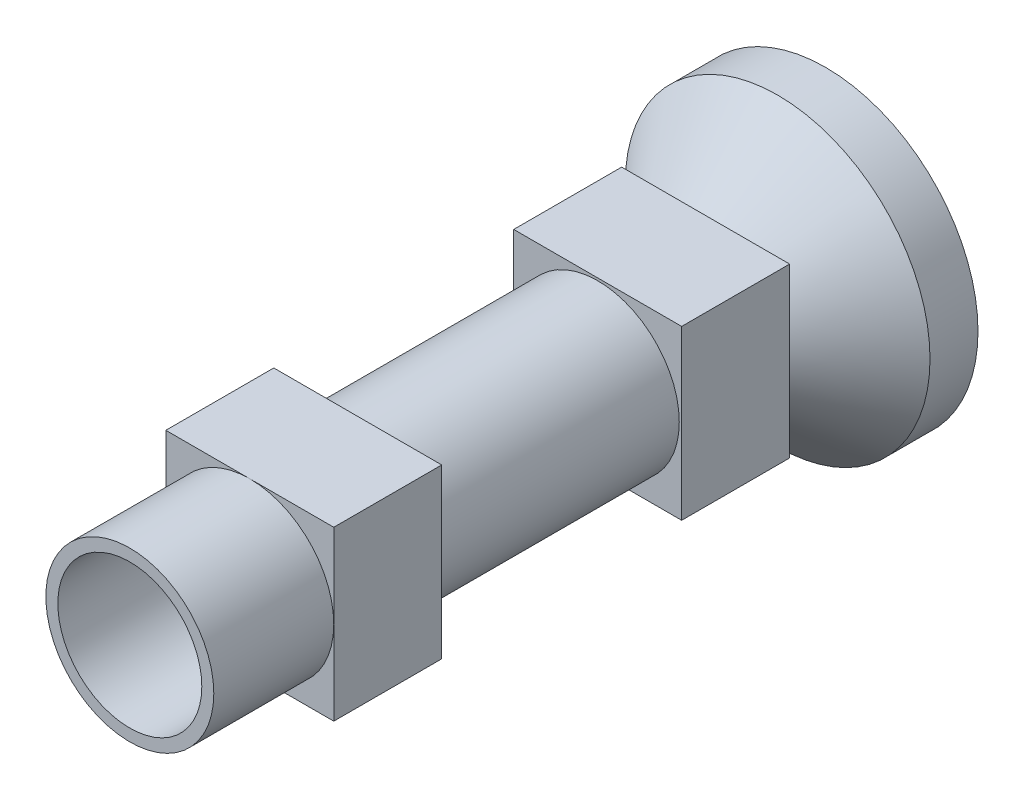
from build123d import *

# Parameters (mm, degrees)
SKETCH_2_R               = 3.5
EXTRUDE_3_DEPTH          = 19
SKETCH_1_R               = 6.35
EXTRUDE_4_DEPTH          = 2
SKETCH_5_R               = 3.5
EXTRUDE_5_DEPTH          = 2
SKETCH_6_R               = 2.75
CUT_EXTRUDE_1_DEPTH      = 3
SKETCH_7_R               = 1.8
CUT_EXTRUDE_2_DEPTH      = 28.507180927
SKETCH_8_R               = 3
CUT_EXTRUDE_3_DEPTH      = 23
CUT_EXTRUDE_5_DEPTH      = 3
SKETCH_14_W              = 7
SKETCH_14_H              = 7
SKETCH_14_R              = 3.4
EXTRUDE_7_DEPTH          = 19
SKETCH_16_W              = 7
SKETCH_16_H              = 7
SKETCH_16_R              = 3.4
CUT_EXTRUDE_6_DEPTH      = 5
CUT_EXTRUDE_6_DEPTH_BACK = 5
SKETCH_17_R              = 3
SKETCH_17_R_2            = 1.8
EXTRUDE_8_DEPTH          = 14


with BuildPart() as part:
    # ｽｹｯﾁ2 → ﾎﾞｽ - 押し出し3 (new body)
    with BuildSketch(Plane.XY.offset(5)):
        with Locations(Location((0, 0, 0), (0, 0, 180))):
            Circle(SKETCH_2_R)
    extrude(amount=EXTRUDE_3_DEPTH)


with BuildPart() as body_2:
    # ｽｹｯﾁ1 → ﾎﾞｽ - 押し出し4 (new body)
    with BuildSketch(Plane.XY):
        Circle(SKETCH_1_R)
    extrude(amount=EXTRUDE_4_DEPTH)


    add(part.part)  # loft_1 joins it to this body
    # loft from a face of the part (loft_1)
    loft([body_2.faces().sort_by_distance((0, 0, 2))[0], body_2.faces().sort_by_distance((0, 0, 5))[0]])



with BuildPart() as body_3:
    # ｽｹｯﾁ5 → ﾎﾞｽ - 押し出し5 (new body)
    with BuildSketch(Plane.XY.offset(29)):
        Circle(SKETCH_5_R)
    extrude(amount=-EXTRUDE_5_DEPTH)


with BuildPart() as body_2_1:
    add(body_2.part)

    add(body_3.part)  # loft_2 joins it to this body
    # loft from a face of the part (loft_2)
    loft([body_2_1.faces().sort_by_distance((0, 0, 24))[0], body_2_1.faces().sort_by_distance((0, 0, 27))[0]])

    # ｽｹｯﾁ6 → ｶｯﾄ - 押し出し1 (cut)
    with BuildSketch(Plane(origin=(0, 0, 0), x_dir=(-1, 0, 0), z_dir=(0, 0, -1))):
        Circle(SKETCH_6_R)
    extrude(amount=-CUT_EXTRUDE_1_DEPTH, mode=Mode.SUBTRACT)

    # ｽｹｯﾁ7 → ｶｯﾄ - 押し出し2 (cut, through all)
    with BuildSketch(Plane(origin=(0, 0, 3), x_dir=(-1, 0, 0), z_dir=(0, 0, -1))):
        Circle(SKETCH_7_R)
    extrude(amount=-CUT_EXTRUDE_2_DEPTH, mode=Mode.SUBTRACT)

    # ｽｹｯﾁ8 → ｶｯﾄ - 押し出し3 (cut)
    with BuildSketch(Plane.XY.offset(29)):
        Circle(SKETCH_8_R)
    extrude(amount=-CUT_EXTRUDE_3_DEPTH, mode=Mode.SUBTRACT)

    # ｽｹｯﾁ12 → ｶｯﾄ - 押し出し5 (cut)
    with BuildSketch(Plane(origin=(0, 0, 0), x_dir=(-1, 0, 0), z_dir=(0, 0, -1))):
        with BuildLine():
            Line((0.208139361, 3.042889746), (-0.062598794, 2.749287433))
            ThreePointArc((-0.062598794, 2.749287433), (0.187666637, 2.743589115), (0.436377003, 2.715156554))
            Line((0.436377003, 2.715156554), (0.208139361, 3.042889746))
        make_face()
        with BuildLine():
            Line((1.021382817, 2.873895812), (0.681471411, 2.66422535))
            ThreePointArc((0.681471411, 2.66422535), (0.920918933, 2.591217536), (1.152735431, 2.496738077))
            Line((1.152735431, 2.496738077), (1.021382817, 2.873895812))
        make_face()
        with BuildLine():
            Line((1.758874982, 2.491758174), (1.375, 2.38156986))
            ThreePointArc((1.375, 2.38156986), (1.585870886, 2.246667206), (1.783600746, 2.093147959))
            Line((1.783600746, 2.093147959), (1.758874982, 2.491758174))
        make_face()
        with BuildLine():
            Line((2.365919437, 1.92481823), (1.966551129, 1.922284229))
            ThreePointArc((1.966551129, 1.922284229), (2.133206049, 1.735491847), (2.282184553, 1.534318633))
            Line((2.282184553, 1.534318633), (2.365919437, 1.92481823))
        make_face()
        with BuildLine():
            Line((2.79749447, 1.215123324), (2.412252157, 1.320431571))
            ThreePointArc((2.412252157, 1.320431571), (2.522331079, 1.095602997), (2.611509172, 0.861695912))
            Line((2.611509172, 0.861695912), (2.79749447, 1.215123324))
        make_face()
        with BuildLine():
            Line((3.021592135, 0.41530828), (2.679047477, 0.620648543))
            ThreePointArc((2.679047477, 0.620648543), (2.724386352, 0.374458285), (2.747150103, 0.125165148))
            Line((2.747150103, 0.125165148), (3.021592135, 0.41530828))
        make_face()
        with BuildLine():
            Line((3.021592135, -0.41530828), (2.747150103, -0.125165148))
            ThreePointArc((2.747150103, -0.125165148), (2.724386352, -0.374458285), (2.679047477, -0.620648543))
            Line((2.679047477, -0.620648543), (3.021592135, -0.41530828))
        make_face()
        with BuildLine():
            Line((2.79749447, -1.215123324), (2.611509172, -0.861695912))
            ThreePointArc((2.611509172, -0.861695912), (2.522331079, -1.095602997), (2.412252157, -1.320431571))
            Line((2.412252157, -1.320431571), (2.79749447, -1.215123324))
        make_face()
        with BuildLine():
            Line((2.365919437, -1.92481823), (2.282184553, -1.534318633))
            ThreePointArc((2.282184553, -1.534318633), (2.133206049, -1.735491847), (1.966551129, -1.922284229))
            Line((1.966551129, -1.922284229), (2.365919437, -1.92481823))
        make_face()
        with BuildLine():
            Line((1.758874982, -2.491758174), (1.783600746, -2.093147959))
            ThreePointArc((1.783600746, -2.093147959), (1.585870886, -2.246667206), (1.375, -2.38156986))
            Line((1.375, -2.38156986), (1.758874982, -2.491758174))
        make_face()
        with BuildLine():
            Line((1.021382817, -2.873895812), (1.152735431, -2.496738077))
            ThreePointArc((1.152735431, -2.496738077), (0.920918933, -2.591217536), (0.681471411, -2.66422535))
            Line((0.681471411, -2.66422535), (1.021382817, -2.873895812))
        make_face()
        with BuildLine():
            Line((0.208139361, -3.042889746), (0.436377003, -2.715156554))
            ThreePointArc((0.436377003, -2.715156554), (0.187666637, -2.743589115), (-0.062598794, -2.749287433))
            Line((-0.062598794, -2.749287433), (0.208139361, -3.042889746))
        make_face()
        with BuildLine():
            Line((-0.62054084, -2.986206467), (-0.312345512, -2.73220429))
            ThreePointArc((-0.312345512, -2.73220429), (-0.559504036, -2.692481241), (-0.802026334, -2.630447445))
            Line((-0.802026334, -2.630447445), (-0.62054084, -2.986206467))
        make_face()
        with BuildLine():
            Line((-1.403198365, -2.708049916), (-1.037902788, -2.546616933))
            ThreePointArc((-1.037902788, -2.546616933), (-1.265178854, -2.441684351), (-1.481971249, -2.316519203))
            Line((-1.481971249, -2.316519203), (-1.403198365, -2.708049916))
        make_face()
        with BuildLine():
            Line((-2.081787087, -2.229049691), (-1.686483563, -2.172158648))
            ThreePointArc((-1.686483563, -2.172158648), (-1.877021144, -2.009798902), (-2.052005136, -1.830785329))
            Line((-2.052005136, -1.830785329), (-2.081787087, -2.229049691))
        make_face()
        with BuildLine():
            Line((-2.605979184, -1.584731048), (-2.209985568, -1.636601293))
            ThreePointArc((-2.209985568, -1.636601293), (-2.349653363, -1.428855863), (-2.46985119, -1.209270483))
            Line((-2.46985119, -1.209270483), (-2.605979184, -1.584731048))
        make_face()
        with BuildLine():
            Line((-2.936897726, -0.822880152), (-2.569583052, -0.979664707))
            ThreePointArc((-2.569583052, -0.979664707), (-2.64802254, -0.741941121), (-2.704519679, -0.498069577))
            Line((-2.704519679, -0.498069577), (-2.936897726, -0.822880152))
        make_face()
        with BuildLine():
            Line((-3.05, 0), (-2.738606317, -0.250070871))
            ThreePointArc((-2.738606317, -0.250070871), (-2.75, 0), (-2.738606317, 0.250070871))
            Line((-2.738606317, 0.250070871), (-3.05, 0))
        make_face()
        with BuildLine():
            Line((-2.936897726, 0.822880152), (-2.704519679, 0.498069577))
            ThreePointArc((-2.704519679, 0.498069577), (-2.64802254, 0.741941121), (-2.569583052, 0.979664707))
            Line((-2.569583052, 0.979664707), (-2.936897726, 0.822880152))
        make_face()
        with BuildLine():
            Line((-2.605979184, 1.584731048), (-2.46985119, 1.209270483))
            ThreePointArc((-2.46985119, 1.209270483), (-2.349653363, 1.428855863), (-2.209985568, 1.636601293))
            Line((-2.209985568, 1.636601293), (-2.605979184, 1.584731048))
        make_face()
        with BuildLine():
            Line((-2.081787087, 2.229049691), (-2.052005136, 1.830785329))
            ThreePointArc((-2.052005136, 1.830785329), (-1.877021144, 2.009798902), (-1.686483563, 2.172158648))
            Line((-1.686483563, 2.172158648), (-2.081787087, 2.229049691))
        make_face()
        with BuildLine():
            Line((-1.403198365, 2.708049916), (-1.481971249, 2.316519203))
            ThreePointArc((-1.481971249, 2.316519203), (-1.265178854, 2.441684351), (-1.037902788, 2.546616933))
            Line((-1.037902788, 2.546616933), (-1.403198365, 2.708049916))
        make_face()
        with BuildLine():
            Line((-0.62054084, 2.986206467), (-0.802026334, 2.630447445))
            ThreePointArc((-0.802026334, 2.630447445), (-0.559504036, 2.692481241), (-0.312345512, 2.73220429))
            Line((-0.312345512, 2.73220429), (-0.62054084, 2.986206467))
        make_face()
    extrude(amount=-CUT_EXTRUDE_5_DEPTH, mode=Mode.SUBTRACT)

    # ｽｹｯﾁ14 → ﾎﾞｽ - 押し出し7 (add)
    with BuildSketch(Plane.XY.offset(24)):
        Rectangle(SKETCH_14_W, SKETCH_14_H)
        Circle(SKETCH_14_R, mode=Mode.SUBTRACT)
    extrude(amount=-EXTRUDE_7_DEPTH)

    # ｽｹｯﾁ16 → ｶｯﾄ - 押し出し6 (cut, two sides)
    with BuildSketch(Plane.XY.offset(14.5)) as cut_extrude_6_sk:
        Rectangle(SKETCH_16_W, SKETCH_16_H)
        Circle(SKETCH_16_R, mode=Mode.SUBTRACT)
    extrude(amount=CUT_EXTRUDE_6_DEPTH, mode=Mode.SUBTRACT)
    extrude(cut_extrude_6_sk.sketch, amount=-CUT_EXTRUDE_6_DEPTH_BACK, mode=Mode.SUBTRACT)

    # ｽｹｯﾁ17 → ﾎﾞｽ - 押し出し8 (add)
    with BuildSketch(Plane.XY.offset(6)):
        Circle(SKETCH_17_R)
        with Locations(Location((0, 0, 0), (0, 0, 180))):
            Circle(SKETCH_17_R_2, mode=Mode.SUBTRACT)
    extrude(amount=EXTRUDE_8_DEPTH)


solid = body_2_1.part
